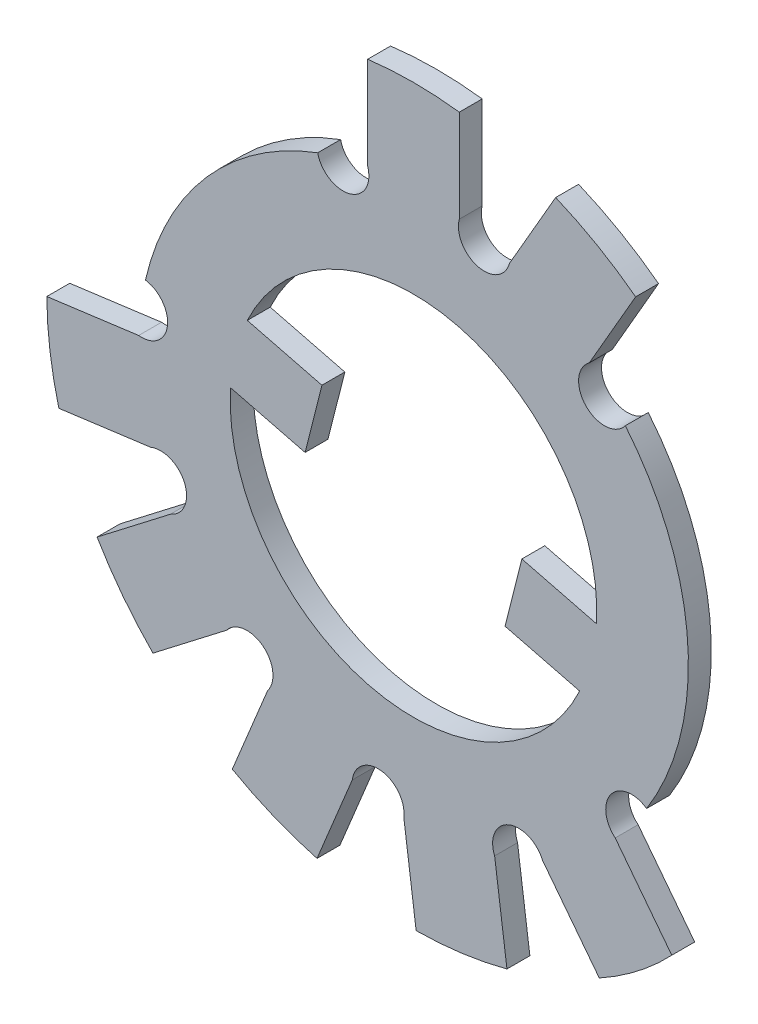
from build123d import *

# Parameters (mm, degrees)
EXTRUSION1_DEPTH = 1


with BuildPart() as part:
    # Esquisse1 → Extrusion1 (new body)
    with BuildSketch(Plane.XY):
        with BuildLine():
            Line((1.99912085, 15.874618604), (1.99912085, 11.830127492))
            ThreePointArc((1.99912085, 11.830127492), (2.802057184, 10.445996528), (4.186188149, 11.248932862))
            Line((4.186188149, 11.248932862), (6.205424959, 14.750775921))
            ThreePointArc((6.205424959, 14.750775921), (8.013684846, 13.856571787), (9.695180285, 12.742131148))
            Line((9.695180285, 12.742131148), (7.674850984, 9.238393448))
            ThreePointArc((7.674850984, 9.238393448), (7.531961719, 7.526490891), (9.245630513, 7.646353187))
            ThreePointArc((9.245630513, 7.646353187), (11.971535209, 0.794194802), (10.174683291, -6.358004449))
            ThreePointArc((10.174683291, -6.358004449), (8.622367496, -6.592697054), (8.80279787, -8.152251421))
            Line((8.80279787, -8.152251421), (11.27300937, -11.35198223))
            ThreePointArc((11.27300937, -11.35198223), (9.784733034, -12.695580008), (8.108156612, -13.795267665))
            Line((8.108156612, -13.795267665), (5.636608626, -10.593805669))
            ThreePointArc((5.636608626, -10.593805669), (4.154539047, -9.981087108), (3.541820486, -11.463156687))
            Line((3.541820486, -11.463156687), (4.079298509, -15.469568982))
            ThreePointArc((4.079298509, -15.469568982), (2.114599048, -15.859646786), (0.116557342, -16.00118833))
            Line((0.116557342, -16.00118833), (-0.42121148, -11.9926084))
            ThreePointArc((-0.42121148, -11.9926084), (-1.397751762, -10.720475015), (-2.669885147, -11.697015298))
            Line((-2.669885147, -11.697015298), (-4.209415427, -15.434670796))
            ThreePointArc((-4.209415427, -15.434670796), (-6.105624465, -14.78922835), (-7.906329329, -13.91192187))
            Line((-7.906329329, -13.91192187), (-6.3659661, -10.172244146))
            ThreePointArc((-6.3659661, -10.172244146), (-6.574845101, -8.58217376), (-8.164915488, -8.791052761))
            Line((-8.164915488, -8.791052761), (-11.3681991, -11.256655367))
            ThreePointArc((-11.3681991, -11.256655367), (-12.686919728, -9.748948309), (-13.806925878, -8.088288533))
            Line((-13.806925878, -8.088288533), (-10.601909158, -5.621351934))
            ThreePointArc((-10.601909158, -5.621351934), (-9.987057643, -4.140165962), (-11.468243615, -3.525314447))
            Line((-11.468243615, -3.525314447), (-15.475425513, -4.05702428))
            ThreePointArc((-15.475425513, -4.05702428), (-15.86267453, -2.091765297), (-16.001339545, -0.093521899))
            Line((-16.001339545, -0.093521899), (-11.991989597, 0.438475611))
            ThreePointArc((-11.991989597, 0.438475611), (-10.737924032, 1.413097931), (-11.69713727, 2.678988555))
            ThreePointArc((-11.69713727, 2.678988555), (-9.021028947, 7.913345483), (-4.179870655, 11.248496846))
            ThreePointArc((-4.179870655, 11.248496846), (-2.783654446, 10.397988514), (-1.99912085, 11.832314545))
            Line((-1.99912085, 11.832314545), (-1.99912085, 15.874618604))
            ThreePointArc((-1.99912085, 15.874618604), (0, 16), (1.99912085, 15.874618604))
        make_face()
        with BuildLine():
            Line((7.986234295, -0.469107442), (4.730272388, 0.352878359))
            Line((4.730272388, 0.352878359), (3.995944926, -2.555860746))
            Line((3.995944926, -2.555860746), (7.251906832, -3.377846547))
            ThreePointArc((7.251906832, -3.377846547), (-1.958206566, -7.756637612), (-7.986234295, 0.469107442))
            Line((-7.986234295, 0.469107442), (-4.730272388, -0.352878359))
            Line((-4.730272388, -0.352878359), (-3.995944926, 2.555860746))
            Line((-3.995944926, 2.555860746), (-7.251906832, 3.377846547))
            ThreePointArc((-7.251906832, 3.377846547), (1.958206566, 7.756637612), (7.986234295, -0.469107442))
        make_face(mode=Mode.SUBTRACT)
    extrude(amount=EXTRUSION1_DEPTH)


solid = part.part
